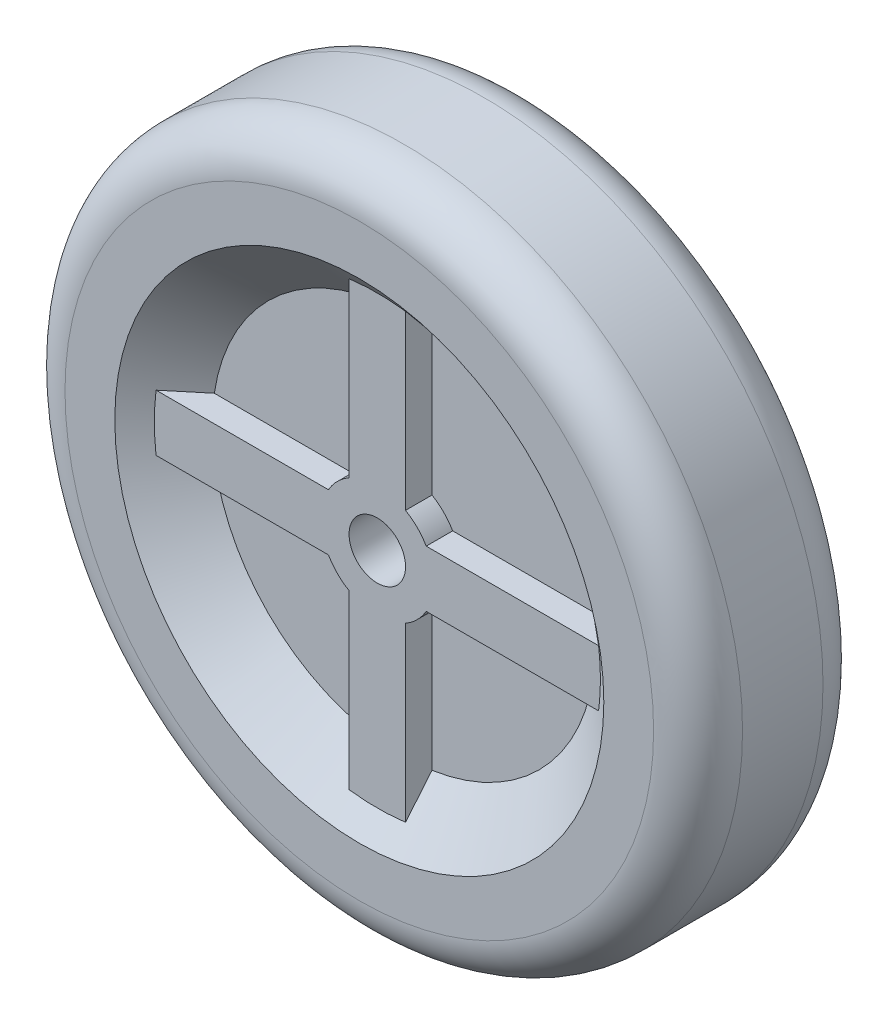
from build123d import *

# Parameters (mm, degrees)
SKETCH1_R               = 76.2
BOSS_EXTRUDE1_DEPTH     = 38.1
FILLET1_R               = 10
SKETCH2_R               = 6.35
CUT_EXTRUDE1_DEPTH      = 38.1
SKETCH3_R               = 55
CUT_EXTRUDE2_DEPTH      = 10
CUT_EXTRUDE2_DRAFT      = -50
MIRROR1_COPY_1_SKETCH_R = 55
MIRROR1_COPY_1_DEPTH    = 10
MIRROR1_COPY_1_DRAFT    = -50
SKETCH4_R               = 6.35
BOSS_EXTRUDE3_DEPTH     = 15


with BuildPart() as part:
    # Sketch1 → Boss-Extrude1 (new body)
    with BuildSketch(Plane.XY):
        with Locations(Location((0, 0, 0), (0, 0, 180))):
            Circle(SKETCH1_R)
    extrude(amount=BOSS_EXTRUDE1_DEPTH)

    # Fillet1
    fillet1_edges = [part.edges().sort_by_distance(p)[0] for p in [
        (76.2, 0, 0),
        (76.2, 0, 38.1),
    ]]
    fillet(fillet1_edges, radius=FILLET1_R)

    # Sketch2 → Cut-Extrude1 (cut)
    with BuildSketch(Plane.XY.offset(38.1)):
        Circle(SKETCH2_R)
    extrude(amount=-CUT_EXTRUDE1_DEPTH, mode=Mode.SUBTRACT)


with BuildPart() as cut_extrude2_tool:
    # Sketch3 → Cut-Extrude2 (with draft: the straight prism first)
    with BuildSketch(Plane.XY.offset(38.1)):
        Circle(SKETCH3_R)
    extrude(amount=-CUT_EXTRUDE2_DEPTH)
    # Cut-Extrude2: the draft: its side faces are tilted about the plane it starts from
    cut_extrude2_sides = [cut_extrude2_tool.faces().sort_by_distance(p)[0] for p in [
        (-55, 0, 33.1),
    ]]
    draft(cut_extrude2_sides, Plane.XY.offset(38.1), CUT_EXTRUDE2_DRAFT)


with BuildPart() as part_1:
    add(part.part)

    # Cut-Extrude2: cut by cut_extrude2_tool
    add(cut_extrude2_tool.part, mode=Mode.SUBTRACT)


with BuildPart() as mirror1_copy_1_tool:
    # Mirror1 copy 1 sketch → Mirror1 copy 1 (with draft: the straight prism first)
    with BuildSketch(Plane(origin=(0, 0, 0), x_dir=(1, 0, 0), z_dir=(0, 0, -1))):
        Circle(MIRROR1_COPY_1_SKETCH_R)
    extrude(amount=-MIRROR1_COPY_1_DEPTH)
    # Mirror1 copy 1: the draft: its side faces are tilted about the plane it starts from
    mirror1_copy_1_sides = [mirror1_copy_1_tool.faces().sort_by_distance(p)[0] for p in [
        (-55, 0, 5),
    ]]
    draft(mirror1_copy_1_sides, Plane(origin=(0, 0, 0), x_dir=(1, 0, 0), z_dir=(0, 0, -1)), MIRROR1_COPY_1_DRAFT)


with BuildPart() as part_2:
    add(part_1.part)

    # Mirror1 copy 1: cut by mirror1_copy_1_tool
    add(mirror1_copy_1_tool.part, mode=Mode.SUBTRACT)

    # Sketch4 → Boss-Extrude3 (add, symmetric)
    with BuildSketch(Plane(origin=(0, 0, 19.05), x_dir=(-1, 0, 0), z_dir=(0, 0, -1))):
        with BuildLine():
            Line((10.998522628, 6.35), (54.632202042, 6.35))
            Line((54.632202042, 6.35), (54.632202042, -6.35))
            Line((54.632202042, -6.35), (10.998522628, -6.35))
            ThreePointArc((10.998522628, -6.35), (8.980256121, -8.980256121), (6.35, -10.998522628))
            Line((6.35, -10.998522628), (6.35, -54.632202042))
            Line((6.35, -54.632202042), (-6.35, -54.632202042))
            Line((-6.35, -54.632202042), (-6.35, -10.998522628))
            ThreePointArc((-6.35, -10.998522628), (-8.980256121, -8.980256121), (-10.998522628, -6.35))
            Line((-10.998522628, -6.35), (-54.632202042, -6.35))
            Line((-54.632202042, -6.35), (-54.632202042, 6.35))
            Line((-54.632202042, 6.35), (-10.998522628, 6.35))
            ThreePointArc((-10.998522628, 6.35), (-8.980256121, 8.980256121), (-6.35, 10.998522628))
            Line((-6.35, 10.998522628), (-6.35, 54.632202042))
            Line((-6.35, 54.632202042), (6.35, 54.632202042))
            Line((6.35, 54.632202042), (6.35, 10.998522628))
            ThreePointArc((6.35, 10.998522628), (8.980256121, 8.980256121), (10.998522628, 6.35))
        make_face()
        with Locations(Location((0, 0, 0), (0, 0, 180))):
            Circle(SKETCH4_R, mode=Mode.SUBTRACT)
    extrude(amount=BOSS_EXTRUDE3_DEPTH, both=True)


solid = part_2.part
